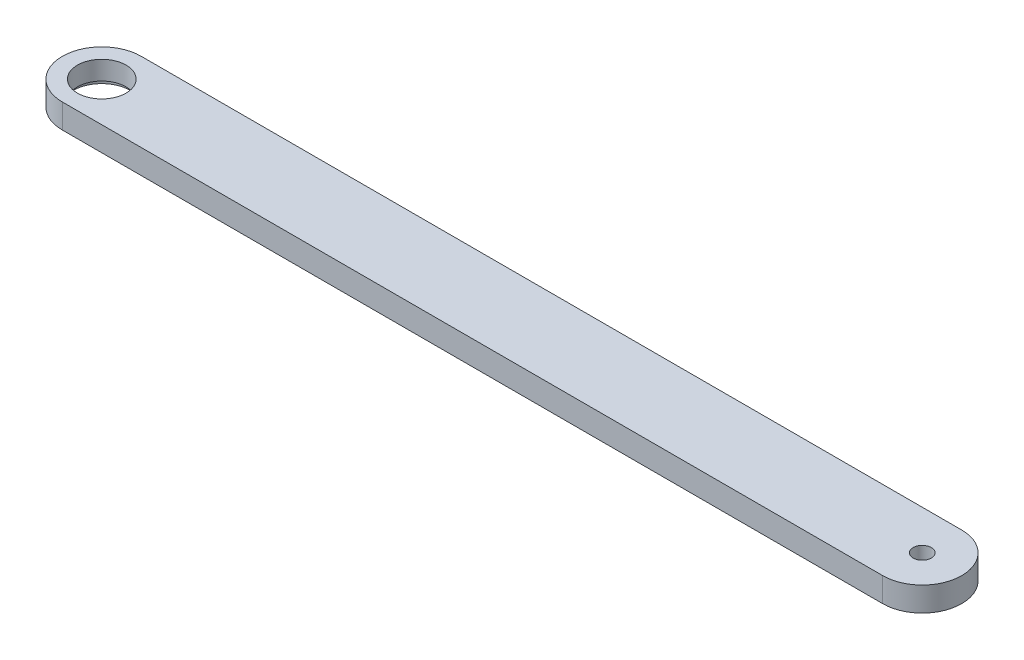
from build123d import *

# Parameters (mm, degrees)
EXTRUDE_1_DEPTH              = 4
HOLE_WIZARD_M5_1_D           = 8
HOLE_WIZARD_M5_1_DEPTH       = 12.4
HOLE_WIZARD_M5_1_CBORE_D     = 9.5
HOLE_WIZARD_M5_1_CBORE_DEPTH = 0.9
HOLE_WIZARD_M5_1_TIP         = 2.403442476
HOLE_WIZARD_M3_1_D           = 3
HOLE_WIZARD_M3_1_DEPTH       = 7.5
HOLE_WIZARD_M3_1_TIP         = 0.901290929


with BuildPart() as part:
    # 草图1 → 凸台-拉伸1 (new body)
    with BuildSketch(Plane(origin=(0, 0, 0), x_dir=(1, 0, 0), z_dir=(0, 1, 0))):
        with BuildLine():
            Line((-67.5, 6.5), (67.5, 6.5))
            ThreePointArc((67.5, 6.5), (74, 0), (67.5, -6.5))
            Line((67.5, -6.5), (-67.5, -6.5))
            ThreePointArc((-67.5, -6.5), (-74, 0), (-67.5, 6.5))
        make_face()
    extrude(amount=EXTRUDE_1_DEPTH)

    # M5 六角头螺栓的柱形沉头孔1
    with Locations(Plane.XZ):
        with Locations((-67.5, 0)):
            CounterBoreHole(HOLE_WIZARD_M5_1_D / 2, HOLE_WIZARD_M5_1_CBORE_D / 2, HOLE_WIZARD_M5_1_CBORE_DEPTH, depth=HOLE_WIZARD_M5_1_DEPTH)
            with Locations((0, 0, -(HOLE_WIZARD_M5_1_DEPTH + HOLE_WIZARD_M5_1_TIP / 2))):  # 118° drill point
                Cone(0, HOLE_WIZARD_M5_1_D / 2, HOLE_WIZARD_M5_1_TIP, mode=Mode.SUBTRACT)

    # M3 螺纹孔1
    with Locations(Plane(origin=(0, 4, 0), x_dir=(1, 0, 0), z_dir=(0, 1, 0))):
        with Locations((67.5, 0)):
            Hole(HOLE_WIZARD_M3_1_D / 2, depth=HOLE_WIZARD_M3_1_DEPTH)
            with Locations((0, 0, -(HOLE_WIZARD_M3_1_DEPTH + HOLE_WIZARD_M3_1_TIP / 2))):  # 118° drill point
                Cone(0, HOLE_WIZARD_M3_1_D / 2, HOLE_WIZARD_M3_1_TIP, mode=Mode.SUBTRACT)


solid = part.part
